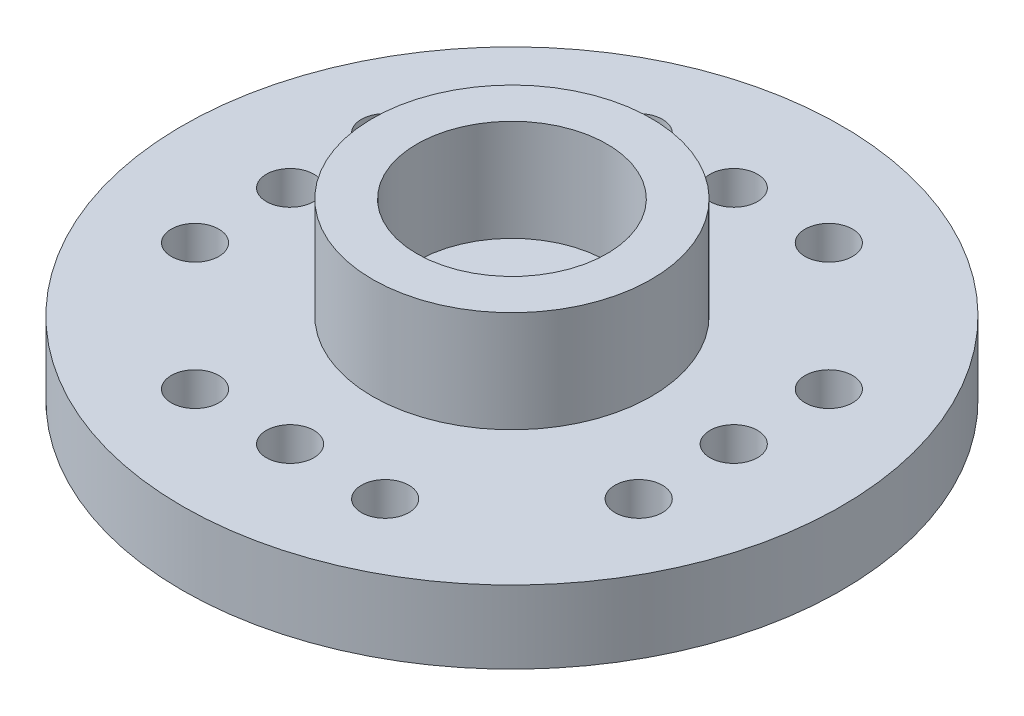
from build123d import *

# Parameters (mm, degrees)
SKETCH1_R           = 10.4
SKETCH1_R_2         = 0.75
SKETCH1_R_3         = 1.5
BOSS_EXTRUDE1_DEPTH = 2.3
SKETCH2_R           = 4.4
SKETCH2_R_2         = 3
BOSS_EXTRUDE2_DEPTH = 3.2


with BuildPart() as part:
    # Sketch1 → Boss-Extrude1 (new body)
    with BuildSketch(Plane(origin=(0, 0, 0), x_dir=(1, 0, 0), z_dir=(0, 1, 0))):
        Circle(SKETCH1_R)
        with Locations((7, 0)):
            Circle(SKETCH1_R_2, mode=Mode.SUBTRACT)
        with Locations((7, 3)):
            Circle(SKETCH1_R_2, mode=Mode.SUBTRACT)
        with Locations((7, -3)):
            Circle(SKETCH1_R_2, mode=Mode.SUBTRACT)
        with Locations((3, -7)):
            Circle(SKETCH1_R_2, mode=Mode.SUBTRACT)
        with Locations((0, -7)):
            Circle(SKETCH1_R_2, mode=Mode.SUBTRACT)
        with Locations((-3, -7)):
            Circle(SKETCH1_R_2, mode=Mode.SUBTRACT)
        with Locations((-7, -3)):
            Circle(SKETCH1_R_2, mode=Mode.SUBTRACT)
        with Locations((-7, 0)):
            Circle(SKETCH1_R_2, mode=Mode.SUBTRACT)
        with Locations((-7, 3)):
            Circle(SKETCH1_R_2, mode=Mode.SUBTRACT)
        with Locations((-3, 7)):
            Circle(SKETCH1_R_2, mode=Mode.SUBTRACT)
        with Locations((0, 7)):
            Circle(SKETCH1_R_2, mode=Mode.SUBTRACT)
        with Locations((3, 7)):
            Circle(SKETCH1_R_2, mode=Mode.SUBTRACT)
        Circle(SKETCH1_R_3, mode=Mode.SUBTRACT)
    extrude(amount=BOSS_EXTRUDE1_DEPTH)

    # Sketch2 → Boss-Extrude2 (add)
    with BuildSketch(Plane(origin=(0, 2.3, 0), x_dir=(1, 0, 0), z_dir=(0, 1, 0))):
        Circle(SKETCH2_R)
        Circle(SKETCH2_R_2, mode=Mode.SUBTRACT)
    extrude(amount=BOSS_EXTRUDE2_DEPTH)


solid = part.part
